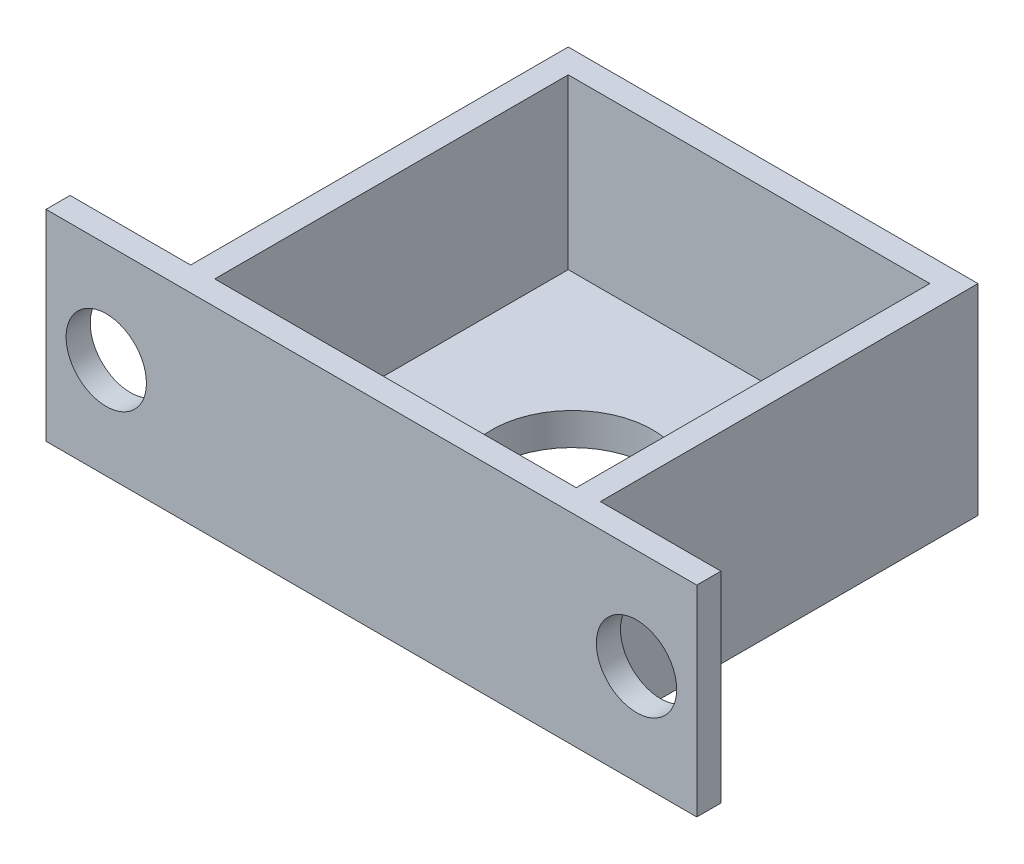
from build123d import *

# Parameters (mm, degrees)
SKETCH_1_W          = 51
SKETCH_1_H          = 50
EXTRUDE_1_DEPTH     = 25
SKETCH_2_R          = 10
CUT_EXTRUDE_1_DEPTH = 26
SKETCH_3_W          = 45
SKETCH_3_H          = 44
CUT_EXTRUDE_2_DEPTH = 21
SKETCH_4_W          = 81
SKETCH_4_H          = 25
SKETCH_4_R          = 5
EXTRUDE_2_DEPTH     = 3


with BuildPart() as part:
    # 草圖1 → 填料-伸長1 (new body)
    with BuildSketch(Plane(origin=(0, 0, 0), x_dir=(1, 0, 0), z_dir=(0, 1, 0))):
        Rectangle(SKETCH_1_W, SKETCH_1_H)
    extrude(amount=EXTRUDE_1_DEPTH)

    # 草圖2 → 除料-伸長1 (cut, through all)
    with BuildSketch(Plane(origin=(0, 25, 0), x_dir=(1, 0, 0), z_dir=(0, 1, 0))):
        Circle(SKETCH_2_R)
    extrude(amount=-CUT_EXTRUDE_1_DEPTH, mode=Mode.SUBTRACT)

    # 草圖3 → 除料-伸長2 (cut)
    with BuildSketch(Plane(origin=(0, 25, 0), x_dir=(1, 0, 0), z_dir=(0, 1, 0))):
        Rectangle(SKETCH_3_W, SKETCH_3_H)
    extrude(amount=-CUT_EXTRUDE_2_DEPTH, mode=Mode.SUBTRACT)

    # 草圖4 → 填料-伸長2 (add)
    with BuildSketch(Plane(origin=(0, 0, 22), x_dir=(-1, 0, 0), z_dir=(0, 0, -1))):
        with Locations((0, 12.5)):
            Rectangle(SKETCH_4_W, SKETCH_4_H)
        with Locations((-33, 12.5)):
            Circle(SKETCH_4_R, mode=Mode.SUBTRACT)
        with Locations((33, 12.5)):
            Circle(SKETCH_4_R, mode=Mode.SUBTRACT)
    extrude(amount=-EXTRUDE_2_DEPTH)


solid = part.part
